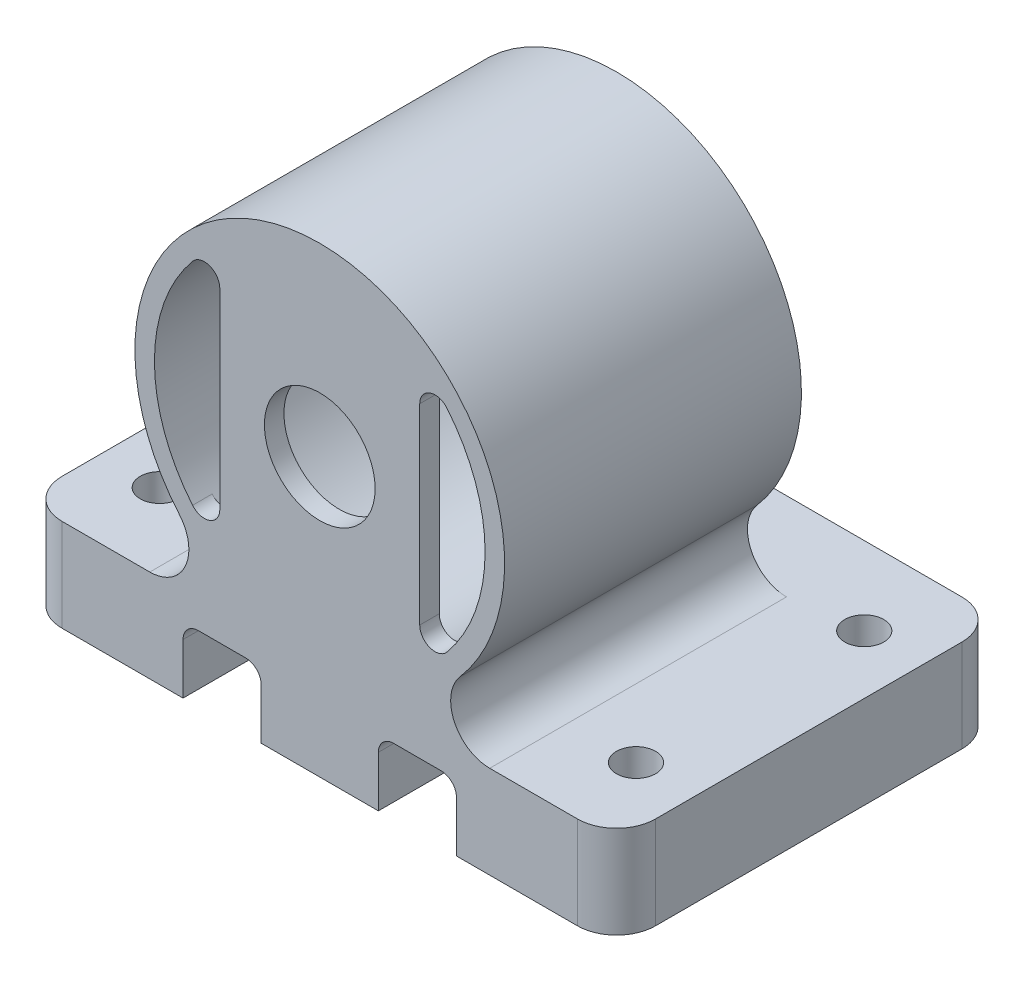
from build123d import *

# Parameters (mm, degrees)
SKETCH2_R           = 12.02
SKETCH2_R_2         = 10.75
BOSS_EXTRUDE1_DEPTH = 19.3
SKETCH3_R           = 3.6
BOSS_EXTRUDE4_DEPTH = 1.27
BOSS_EXTRUDE5_DEPTH = 6.02
BOSS_EXTRUDE6_DEPTH = 19.3
CUT_EXTRUDE1_DEPTH  = 26
SKETCH7_R           = 1.27
CUT_EXTRUDE2_DEPTH  = 31.06


with BuildPart() as part:
    # Sketch2 → Boss-Extrude1 (new body)
    with BuildSketch(Plane.XY):
        Circle(SKETCH2_R)
        Circle(SKETCH2_R_2, mode=Mode.SUBTRACT)
    extrude(amount=BOSS_EXTRUDE1_DEPTH)

    # Sketch3 → Boss-Extrude4 (add)
    with BuildSketch(Plane.XY.offset(19.3)):
        with BuildLine():
            Line((-6.5, -6.229967897), (-6.5, 6.229967897))
            ThreePointArc((-6.5, 6.229967897), (-7.16031689, 7.17050784), (-8.269230769, 6.868938964))
            ThreePointArc((-8.269230769, 6.868938964), (0, 10.75), (8.269230769, 6.868938964))
            ThreePointArc((8.269230769, 6.868938964), (7.16031689, 7.17050784), (6.5, 6.229967897))
            Line((6.5, 6.229967897), (6.5, -6.229967897))
            ThreePointArc((6.5, -6.229967897), (7.16031689, -7.17050784), (8.269230769, -6.868938964))
            ThreePointArc((8.269230769, -6.868938964), (0, -10.75), (-8.269230769, -6.868938964))
            ThreePointArc((-8.269230769, -6.868938964), (-7.16031689, -7.17050784), (-6.5, -6.229967897))
        make_face()
        Circle(SKETCH3_R, mode=Mode.SUBTRACT)
    extrude(amount=-BOSS_EXTRUDE4_DEPTH)



with BuildPart() as body_2:
    # Sketch4 → Boss-Extrude5 (new body)
    with BuildSketch(Plane(origin=(0, -12.02, 0), x_dir=(1, 0, 0), z_dir=(0, 1, 0))):
        with BuildLine():
            Line((-12.02, -19.3), (12.02, -19.3))
            Line((12.02, -19.3), (16.755, -19.3))
            ThreePointArc((16.755, -19.3), (18.551051224, -18.556051224), (19.295, -16.76))
            Line((19.295, -16.76), (19.295, 3.16))
            ThreePointArc((19.295, 3.16), (18.551051224, 4.956051224), (16.755, 5.7))
            Line((16.755, 5.7), (-16.755, 5.7))
            ThreePointArc((-16.755, 5.7), (-18.551051224, 4.956051224), (-19.295, 3.16))
            Line((-19.295, 3.16), (-19.295, -16.76))
            ThreePointArc((-19.295, -16.76), (-18.551051224, -18.556051224), (-16.755, -19.3))
            Line((-16.755, -19.3), (-12.02, -19.3))
        make_face()
    extrude(amount=-BOSS_EXTRUDE5_DEPTH)


with BuildPart() as part_1:
    add(part.part)

    add(body_2.part)  # Boss-Extrude6 merges body 2
    # Sketch5 → Boss-Extrude6 (add)
    with BuildSketch(Plane.XY.offset(19.3)):
        with BuildLine():
            Line((-10, -12.02), (-11.050936612, -12.02))
            ThreePointArc((-11.050936612, -12.02), (-8.743098915, -10.540888856), (-9.123094648, -7.826208791))
            ThreePointArc((-9.123094648, -7.826208791), (0, -12.02), (9.123094648, -7.826208791))
            ThreePointArc((9.123094648, -7.826208791), (8.743098915, -10.540888856), (11.050936612, -12.02))
            Line((11.050936612, -12.02), (10, -12.02))
            Line((10, -12.02), (10, -18.04))
            Line((10, -18.04), (-10, -18.04))
            Line((-10, -18.04), (-10, -12.02))
        make_face()
    extrude(amount=-BOSS_EXTRUDE6_DEPTH)

    # Sketch6 → Cut-Extrude1 (cut, through all)
    with BuildSketch(Plane.XY.offset(19.3)):
        with BuildLine():
            Line((-8.89, -18.04), (-8.89, -14.74))
            ThreePointArc((-8.89, -14.74), (-8.597106781, -14.032893219), (-7.89, -13.74))
            Line((-7.89, -13.74), (-4.81, -13.74))
            ThreePointArc((-4.81, -13.74), (-4.102893219, -14.032893219), (-3.81, -14.74))
            Line((-3.81, -14.74), (-3.81, -18.04))
            Line((-3.81, -18.04), (-8.89, -18.04))
        make_face()
        with BuildLine():
            Line((3.81, -14.74), (3.81, -18.04))
            Line((3.81, -18.04), (8.89, -18.04))
            Line((8.89, -18.04), (8.89, -14.74))
            ThreePointArc((8.89, -14.74), (8.597106781, -14.032893219), (7.89, -13.74))
            Line((7.89, -13.74), (4.81, -13.74))
            ThreePointArc((4.81, -13.74), (4.102893219, -14.032893219), (3.81, -14.74))
        make_face()
    extrude(amount=-CUT_EXTRUDE1_DEPTH, mode=Mode.SUBTRACT)

    # Sketch7 → Cut-Extrude2 (cut, through all)
    with BuildSketch(Plane.XZ.offset(18.04)):
        with Locations((-15.485, 14.22)):
            Circle(SKETCH7_R)
        with Locations((15.485, 14.22)):
            Circle(SKETCH7_R)
        with Locations((-15.485, -0.62)):
            Circle(SKETCH7_R)
        with Locations((15.485, -0.62)):
            Circle(SKETCH7_R)
    extrude(amount=-CUT_EXTRUDE2_DEPTH, mode=Mode.SUBTRACT)


solid = part_1.part
